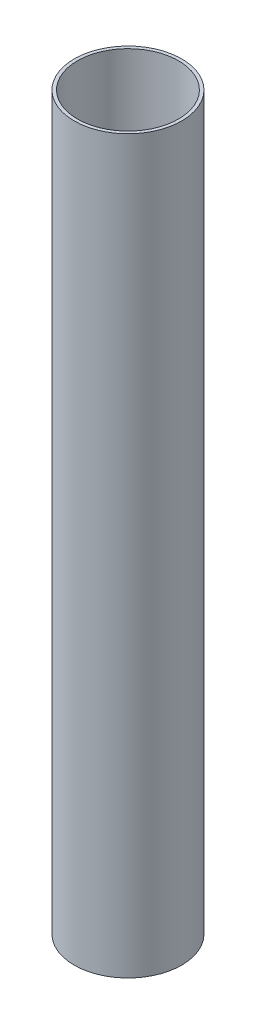
from build123d import *

# Parameters (mm, degrees)
SKETCH1_R           = 50
SKETCH1_R_2         = 47
BOSS_EXTRUDE1_DEPTH = 680


with BuildPart() as part:
    # Sketch1 → Boss-Extrude1 (new body)
    with BuildSketch(Plane(origin=(0, 0, 0), x_dir=(1, 0, 0), z_dir=(0, 1, 0))):
        Circle(SKETCH1_R)
        Circle(SKETCH1_R_2, mode=Mode.SUBTRACT)
    extrude(amount=BOSS_EXTRUDE1_DEPTH)


solid = part.part
